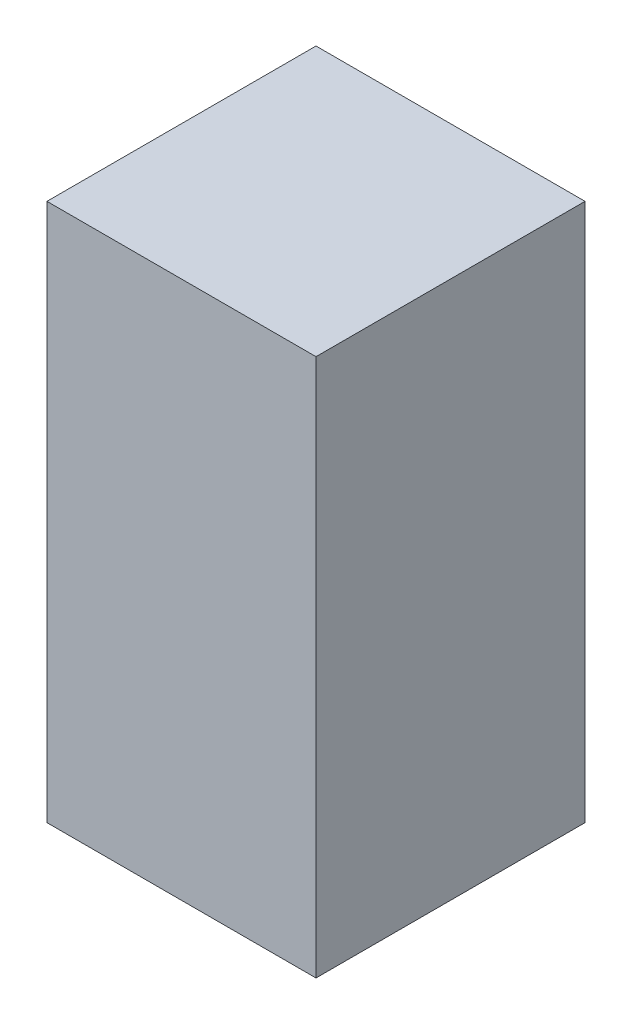
from build123d import *

# Parameters (mm, degrees)
SKETCH1_W           = 50
SKETCH1_H           = 50
BOSS_EXTRUDE1_DEPTH = 100


with BuildPart() as part:
    # Sketch1 → Boss-Extrude1 (new body)
    with BuildSketch(Plane(origin=(0, 0, 0), x_dir=(1, 0, 0), z_dir=(0, 1, 0))):
        with Locations((25, 25)):
            Rectangle(SKETCH1_W, SKETCH1_H)
    extrude(amount=BOSS_EXTRUDE1_DEPTH)


solid = part.part
